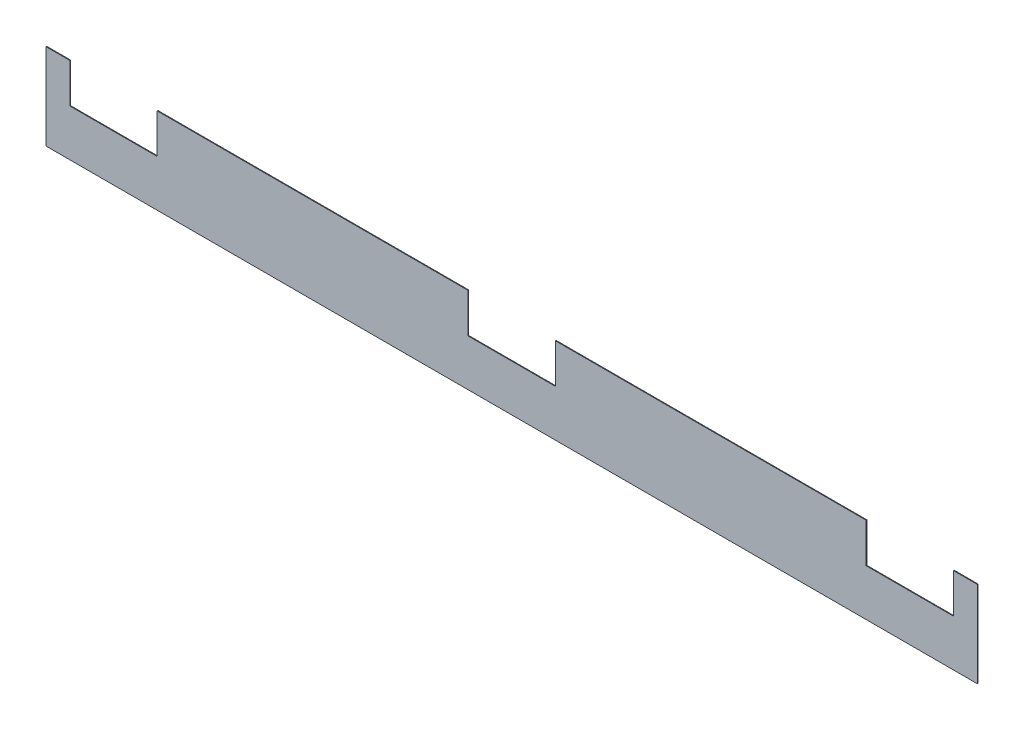
from build123d import *

# Parameters (mm, degrees)
BOSS_EXTRU_1_DEPTH = 3


with BuildPart() as part:
    # Esquisse1 → Boss.-Extru.1 (new body)
    with BuildSketch(Plane.XY):
        Polygon((0, 0), (-3895, 0), (-3895, 360), (-3795, 360), (-3795, 195), (-3430, 195), (-3430, 360), (-2130, 360), (-2130, 195), (-1765, 195), (-1765, 360), (-465, 360), (-465, 195), (-100, 195), (-100, 360), (0, 360), align=None)
    extrude(amount=BOSS_EXTRU_1_DEPTH)


solid = part.part
